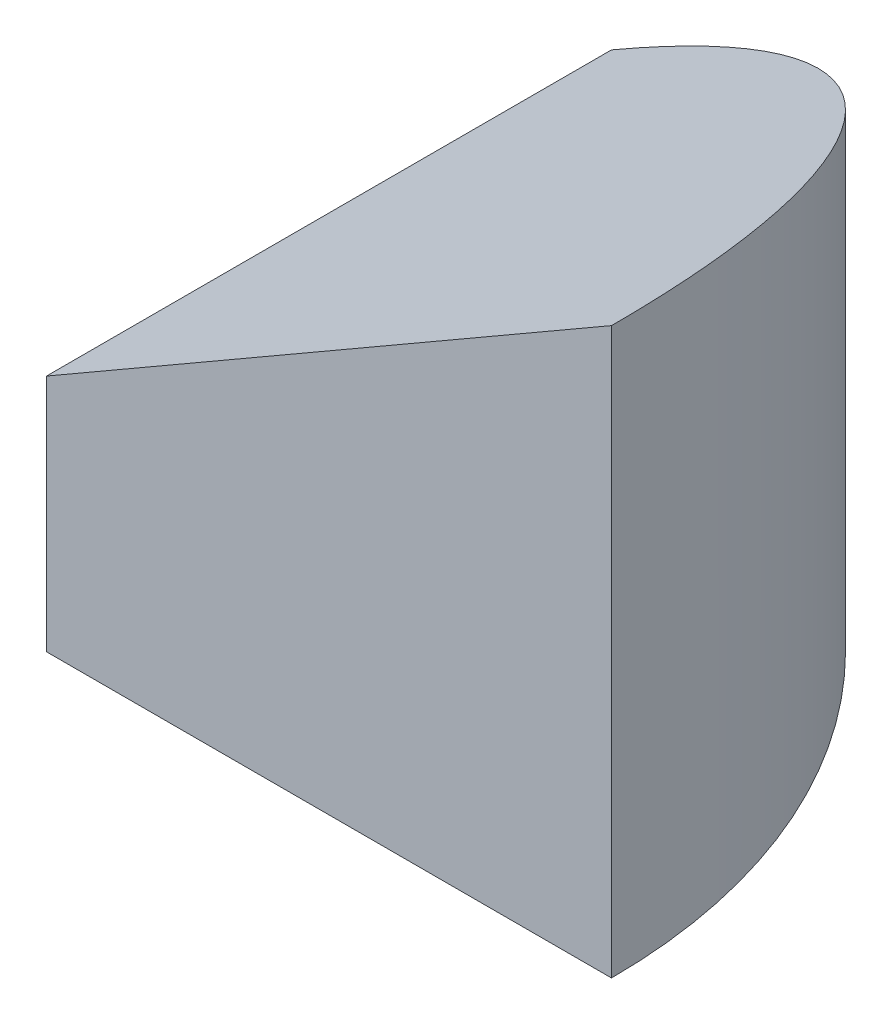
from build123d import *

# Parameters (mm, degrees)
ESBO_O1_R                = 30
RESSALTO_EXTRUS_O1_DEPTH = 30
CORTE_EXTRUS_O1_DEPTH    = 30
CORTE_EXTRUS_O2_DEPTH    = 31


with BuildPart() as part:
    # Esboço1 → Ressalto-extrusão1 (new body)
    with BuildSketch(Plane(origin=(0, 0, 0), x_dir=(1, 0, 0), z_dir=(0, 1, 0))):
        Circle(ESBO_O1_R)
    extrude(amount=RESSALTO_EXTRUS_O1_DEPTH)

    # Esboço2 → Corte-extrusão1 (cut)
    with BuildSketch(Plane(origin=(0, 30, 0), x_dir=(1, 0, 0), z_dir=(0, 1, 0))):
        with BuildLine():
            Line((0, 30), (0, 0))
            Line((0, 0), (30, 0))
            ThreePointArc((30, 0), (-21.213203436, -21.213203436), (0, 30))
        make_face()
    extrude(amount=-CORTE_EXTRUS_O1_DEPTH, mode=Mode.SUBTRACT)

    # Esboço3 → Corte-extrusão2 (cut, through all)
    with BuildSketch(Plane.XY):
        Polygon((30, 30), (0, 12.679491924), (0, 30), align=None)
    extrude(amount=-CORTE_EXTRUS_O2_DEPTH, mode=Mode.SUBTRACT)


solid = part.part
